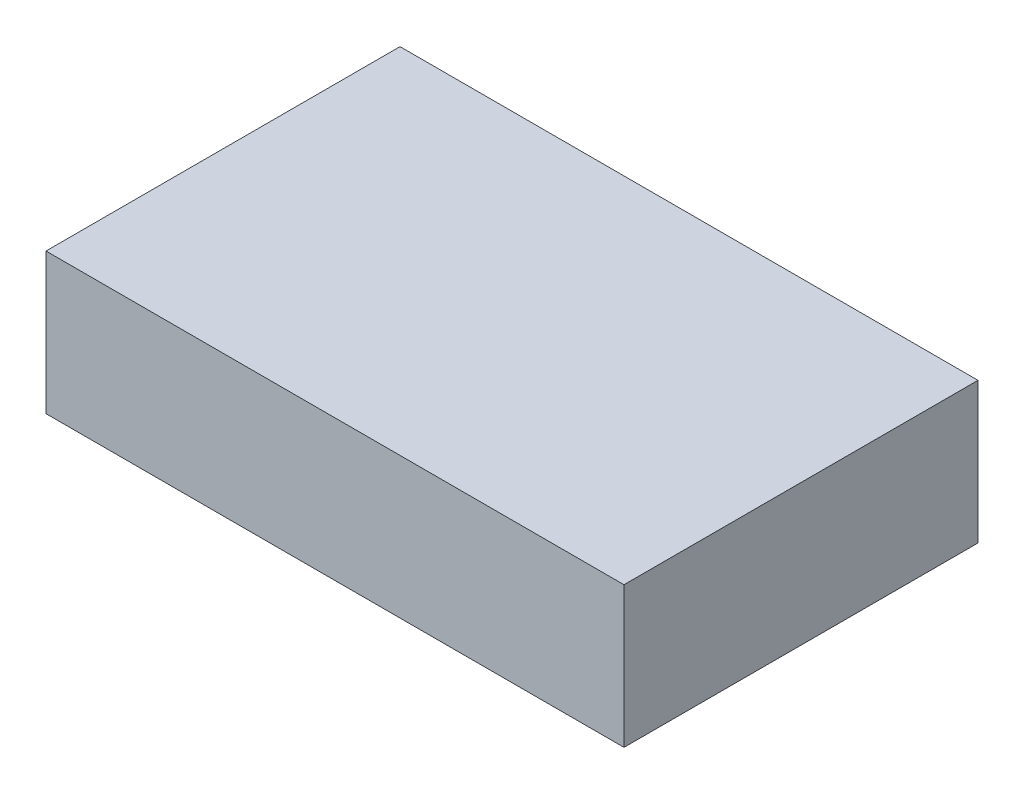
from build123d import *

# Parameters (mm, degrees)
SKETCH1_W                = 160
SKETCH1_H                = 98
BOSS_EXTRUDE1_DEPTH      = 39
M3_CLEARANCE_HOLE1_D     = 3.6
M3_CLEARANCE_HOLE1_DEPTH = 20
M3_CLEARANCE_HOLE1_TIP   = 1.081549114


with BuildPart() as part:
    # Sketch1 → Boss-Extrude1 (new body)
    with BuildSketch(Plane(origin=(0, 0, 0), x_dir=(1, 0, 0), z_dir=(0, 1, 0))):
        Rectangle(SKETCH1_W, SKETCH1_H)
    extrude(amount=BOSS_EXTRUDE1_DEPTH)

    # M3 Clearance Hole1
    with Locations(Plane(origin=(0, 0, 0), x_dir=(-1, 0, 0), z_dir=(0, -1, 0))):
        with Locations((-75, 44), (77, -43)):
            Hole(M3_CLEARANCE_HOLE1_D / 2, depth=M3_CLEARANCE_HOLE1_DEPTH)
            with Locations((0, 0, -(M3_CLEARANCE_HOLE1_DEPTH + M3_CLEARANCE_HOLE1_TIP / 2))):  # 118° drill point
                Cone(0, M3_CLEARANCE_HOLE1_D / 2, M3_CLEARANCE_HOLE1_TIP, mode=Mode.SUBTRACT)


solid = part.part
